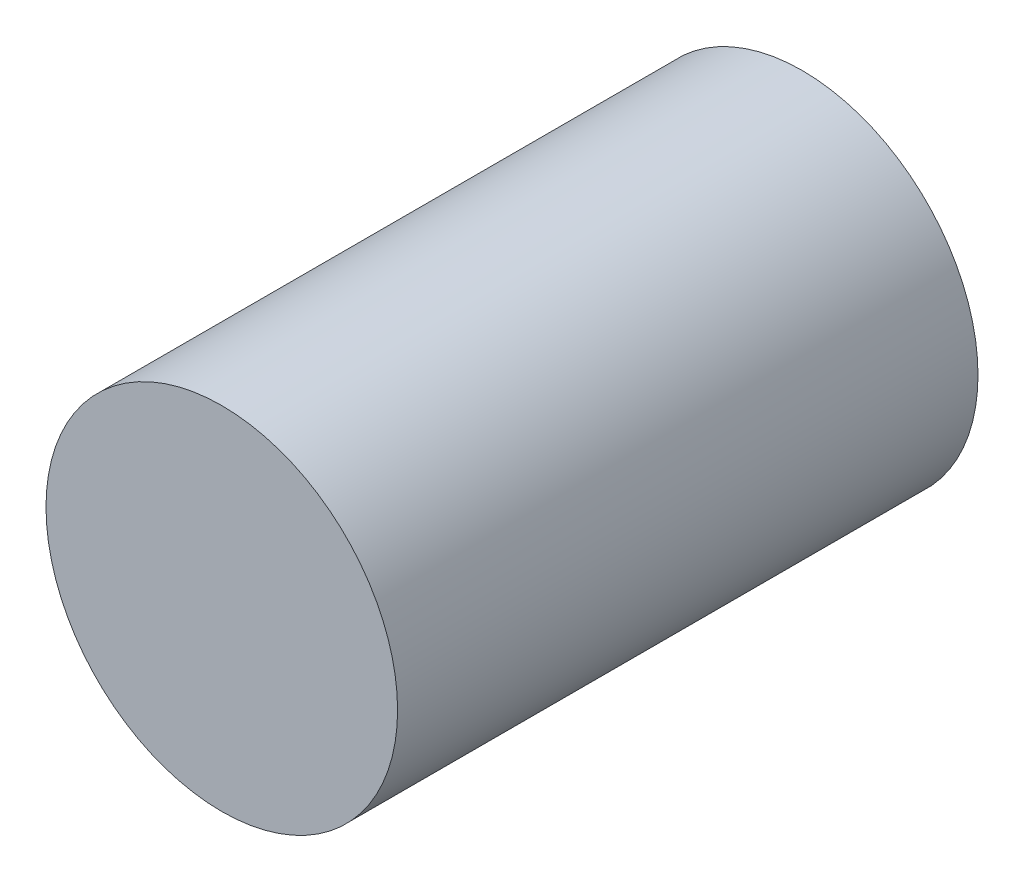
from build123d import *

# Parameters (mm, degrees)
SKETCH1_R           = 0.9995
BOSS_EXTRUDE1_DEPTH = 3.3


with BuildPart() as part:
    # Sketch1 → Boss-Extrude1 (new body)
    with BuildSketch(Plane.XY):
        Circle(SKETCH1_R)
    extrude(amount=BOSS_EXTRUDE1_DEPTH)


solid = part.part
